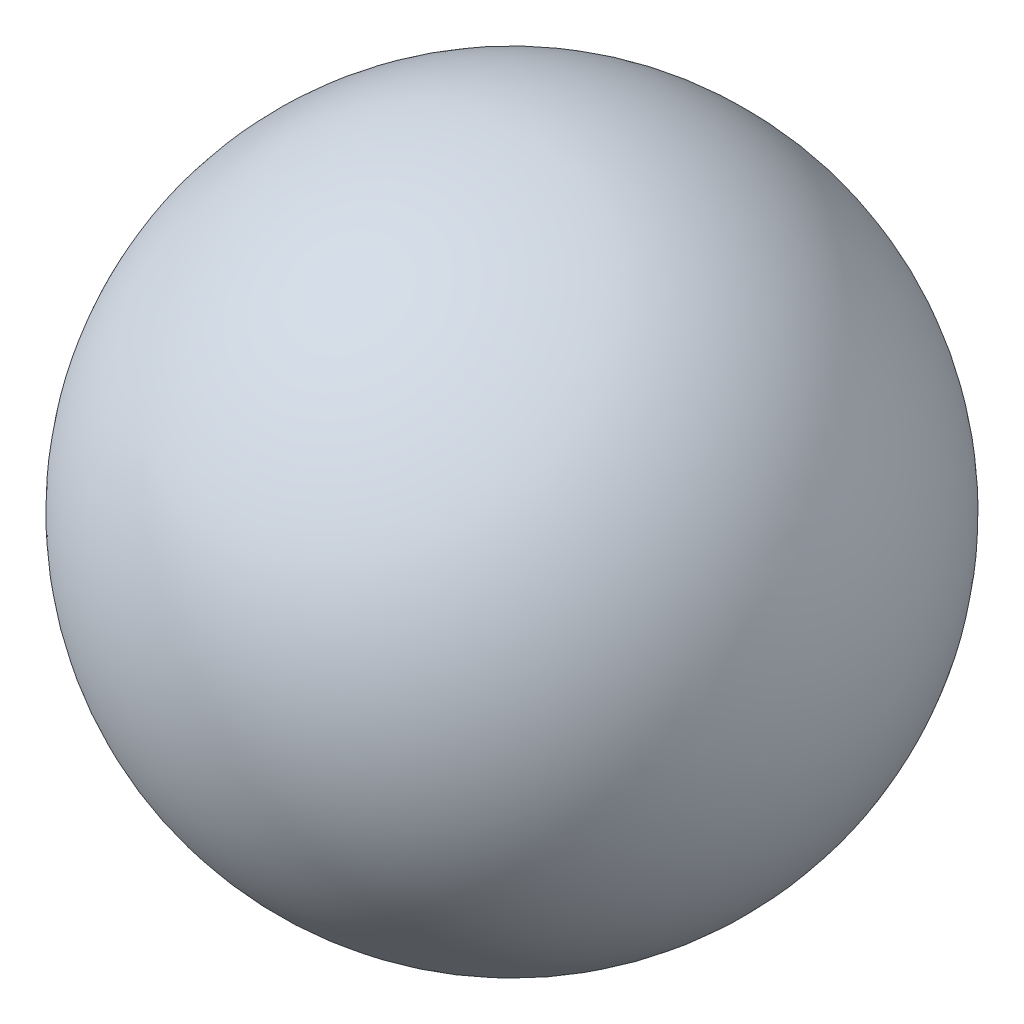
from build123d import *


with BuildPart() as part:
    # Sketch1 → Revolve4 (revolve)
    with BuildSketch(Plane.XY):
        with BuildLine():
            Line((-76.2, 0), (76.2, 0))
            ThreePointArc((76.2, 0), (0, 76.2), (-76.2, 0))
        make_face()
    revolve(axis=Axis((-76.2, 0, 0), (1, 0, 0)))


solid = part.part
